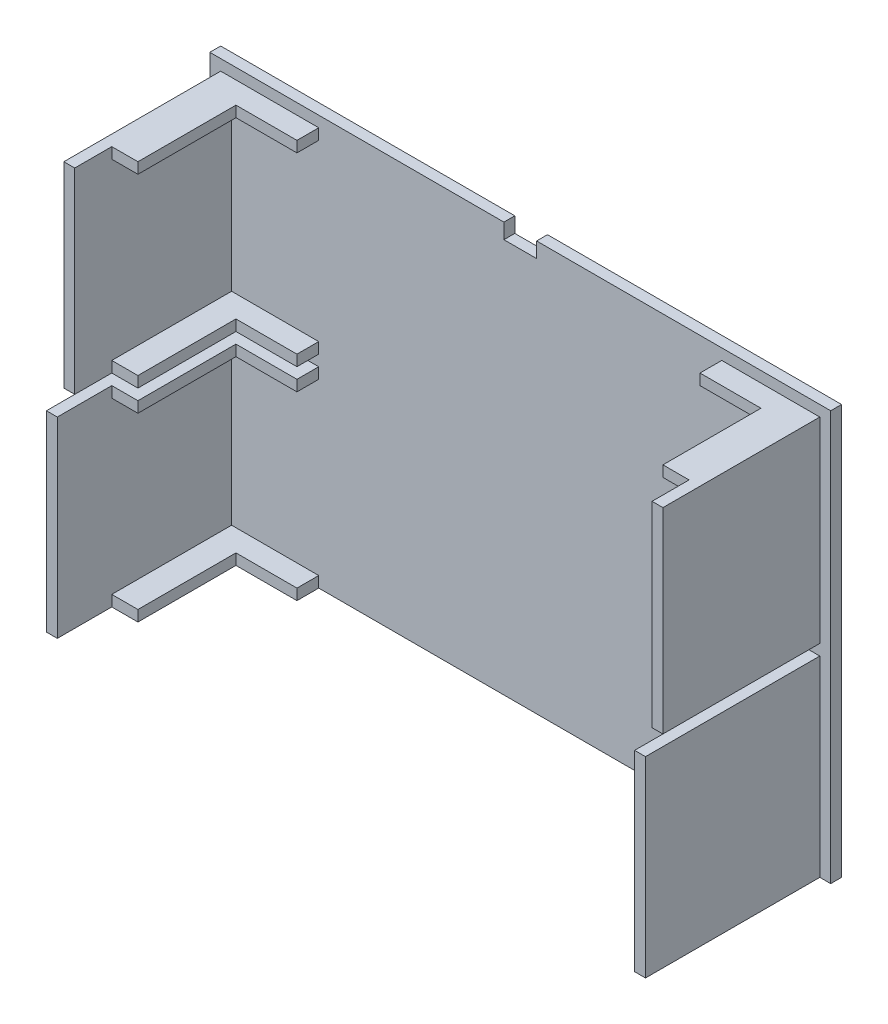
from build123d import *

# Parameters (mm, degrees)
SKETCH1_W                = 285
SKETCH1_H                = 188
BOSS_EXTRUDE1_DEPTH      = 5
SKETCH3_W                = 5
SKETCH3_H                = 90
BOSS_EXTRUDE2_DEPTH      = 72
SKETCH6_W                = 40
SKETCH6_H                = 5
BOSS_EXTRUDE3_DEPTH      = 10
SKETCH7_W                = 12
SKETCH7_H                = 5
BOSS_EXTRUDE4_DEPTH      = 45
SKETCH8_W                = 40
SKETCH8_H                = 5
BOSS_EXTRUDE5_DEPTH      = 72
CUT_EXTRUDE4_DEPTH       = 94
CUT_EXTRUDE4_DEPTH_BACK  = 96
SKETCH13_W               = 5
SKETCH13_H               = 90
BOSS_EXTRUDE6_DEPTH      = 72
SKETCH14_W               = 40
SKETCH14_H               = 5
BOSS_EXTRUDE7_DEPTH      = 55
SKETCH16_W               = 28
SKETCH16_H               = 45
CUT_EXTRUDE5_DEPTH       = 179
CUT_EXTRUDE5_DEPTH_BACK  = 11
SKETCH17_W               = 40
SKETCH17_H               = 5
BOSS_EXTRUDE9_DEPTH      = 55
SKETCH21_W               = 27.761976985
SKETCH21_H               = 40
CUT_EXTRUDE6_DEPTH       = 91
CUT_EXTRUDE6_DEPTH_BACK  = 99
SKETCH22_W               = 5
SKETCH22_H               = 88
BOSS_EXTRUDE10_DEPTH     = 80
SKETCH23_W               = 40
SKETCH23_H               = 5
BOSS_EXTRUDE11_DEPTH     = 55
SKETCH25_W               = 27.891782469
SKETCH25_H               = 44.37316573
CUT_EXTRUDE7_DEPTH       = 184
CUT_EXTRUDE7_DEPTH_BACK  = 6
SKETCH26_W               = 40
SKETCH26_H               = 5
BOSS_EXTRUDE12_DEPTH     = 55
SKETCH27_W               = 28
SKETCH27_H               = 45
CUT_EXTRUDE9_DEPTH       = 101
CUT_EXTRUDE9_DEPTH_BACK  = 89
SKETCH29_W               = 5
SKETCH29_H               = 88
BOSS_EXTRUDE14_DEPTH     = 80
SKETCH30_W               = 40
SKETCH30_H               = 5
BOSS_EXTRUDE15_DEPTH     = 55
SKETCH31_W               = 27.846515173
SKETCH31_H               = 45
CUT_EXTRUDE10_DEPTH      = 184
CUT_EXTRUDE10_DEPTH_BACK = 6
SKETCH32_W               = 40
SKETCH32_H               = 5
BOSS_EXTRUDE16_DEPTH     = 55
SKETCH33_W               = 27.846515173
SKETCH33_H               = 45
CUT_EXTRUDE11_DEPTH      = 84
CUT_EXTRUDE11_DEPTH_BACK = 106
SKETCH36_W               = 15
SKETCH36_H               = 5
CUT_EXTRUDE12_DEPTH      = 1
CUT_EXTRUDE12_DEPTH_BACK = 7


with BuildPart() as part:
    # Sketch1 → Boss-Extrude1 (new body)
    with BuildSketch(Plane.XY):
        with Locations((3.734064661, -18.883040936)):
            Rectangle(SKETCH1_W, SKETCH1_H)
    extrude(amount=BOSS_EXTRUDE1_DEPTH)

    # Sketch3 → Boss-Extrude2 (add)
    with BuildSketch(Plane.XY.offset(5)):
        with Locations((-131.265935339, 25.116959064)):
            Rectangle(SKETCH3_W, SKETCH3_H)
    extrude(amount=BOSS_EXTRUDE2_DEPTH)

    # Sketch6 → Boss-Extrude3 (add)
    with BuildSketch(Plane.XY.offset(5)):
        with Locations((-108.765935339, 67.616959064)):
            Rectangle(SKETCH6_W, SKETCH6_H)
    extrude(amount=BOSS_EXTRUDE3_DEPTH)

    # Sketch7 → Boss-Extrude4 (add)
    with BuildSketch(Plane.XY.offset(15)):
        with Locations((-122.765935339, 67.616959064)):
            Rectangle(SKETCH7_W, SKETCH7_H)
    extrude(amount=BOSS_EXTRUDE4_DEPTH)

    # Sketch8 → Boss-Extrude5 (add)
    with BuildSketch(Plane.XY.offset(77)):
        with Locations((-108.765935339, -17.383040936)):
            Rectangle(SKETCH8_W, SKETCH8_H)
    extrude(amount=-BOSS_EXTRUDE5_DEPTH)

    # Sketch9 → Cut-Extrude4 (cut, two sides)
    with BuildSketch(Plane.XZ.offset(19.883040936)) as cut_extrude4_sk:
        Polygon((-116.765935339, 15), (-88.765935339, 15), (-88.765935339, 77), (-128.765935339, 77), (-128.765935339, 60), (-116.765935339, 60), align=None)
    extrude(amount=CUT_EXTRUDE4_DEPTH, mode=Mode.SUBTRACT)
    extrude(cut_extrude4_sk.sketch, amount=-CUT_EXTRUDE4_DEPTH_BACK, mode=Mode.SUBTRACT)

    # Sketch13 → Boss-Extrude6 (add)
    with BuildSketch(Plane.XY.offset(5)):
        with Locations((138.734064661, 25.116959064)):
            Rectangle(SKETCH13_W, SKETCH13_H)
    extrude(amount=BOSS_EXTRUDE6_DEPTH)

    # Sketch14 → Boss-Extrude7 (add)
    with BuildSketch(Plane.XY.offset(5)):
        with Locations((116.234064661, 67.616959064)):
            Rectangle(SKETCH14_W, SKETCH14_H)
    extrude(amount=BOSS_EXTRUDE7_DEPTH)

    # Sketch16 → Cut-Extrude5 (cut, two sides)
    with BuildSketch(Plane.XZ.offset(-65.116959064)) as cut_extrude5_sk:
        with Locations((110.234064661, 37.5)):
            Rectangle(SKETCH16_W, SKETCH16_H)
    extrude(amount=CUT_EXTRUDE5_DEPTH, mode=Mode.SUBTRACT)
    extrude(cut_extrude5_sk.sketch, amount=-CUT_EXTRUDE5_DEPTH_BACK, mode=Mode.SUBTRACT)

    # Sketch17 → Boss-Extrude9 (add)
    with BuildSketch(Plane.XY):
        with Locations((116.234064661, -17.383040936)):
            Rectangle(SKETCH17_W, SKETCH17_H)
    extrude(amount=BOSS_EXTRUDE9_DEPTH)

    # Sketch21 → Cut-Extrude6 (cut, two sides)
    with BuildSketch(Plane(origin=(0, -14.883040936, 0), x_dir=(1, 0, 0), z_dir=(0, 1, 0))) as cut_extrude6_sk:
        with Locations((110.115053154, -35)):
            Rectangle(SKETCH21_W, SKETCH21_H)
    extrude(amount=CUT_EXTRUDE6_DEPTH, mode=Mode.SUBTRACT)
    extrude(cut_extrude6_sk.sketch, amount=-CUT_EXTRUDE6_DEPTH_BACK, mode=Mode.SUBTRACT)

    # Sketch22 → Boss-Extrude10 (add)
    with BuildSketch(Plane.XY.offset(5)):
        with Locations((-131.265935339, -68.883040936)):
            Rectangle(SKETCH22_W, SKETCH22_H)
    extrude(amount=BOSS_EXTRUDE10_DEPTH)

    # Sketch23 → Boss-Extrude11 (add)
    with BuildSketch(Plane.XY.offset(5)):
        with Locations((-108.765935339, -110.383040936)):
            Rectangle(SKETCH23_W, SKETCH23_H)
    extrude(amount=BOSS_EXTRUDE11_DEPTH)

    # Sketch25 → Cut-Extrude7 (cut, two sides)
    with BuildSketch(Plane(origin=(0, -107.883040936, 0), x_dir=(1, 0, 0), z_dir=(0, 1, 0))) as cut_extrude7_sk:
        with Locations((-102.711826574, -37.813417135)):
            Rectangle(SKETCH25_W, SKETCH25_H)
    extrude(amount=CUT_EXTRUDE7_DEPTH, mode=Mode.SUBTRACT)
    extrude(cut_extrude7_sk.sketch, amount=-CUT_EXTRUDE7_DEPTH_BACK, mode=Mode.SUBTRACT)

    # Sketch26 → Boss-Extrude12 (add)
    with BuildSketch(Plane.XY.offset(5)):
        with Locations((-108.765935339, -27.383040936)):
            Rectangle(SKETCH26_W, SKETCH26_H)
    extrude(amount=BOSS_EXTRUDE12_DEPTH)

    # Sketch27 → Cut-Extrude9 (cut, two sides)
    with BuildSketch(Plane(origin=(0, -24.883040936, 0), x_dir=(1, 0, 0), z_dir=(0, 1, 0))) as cut_extrude9_sk:
        with Locations((-102.765935339, -37.5)):
            Rectangle(SKETCH27_W, SKETCH27_H)
    extrude(amount=CUT_EXTRUDE9_DEPTH, mode=Mode.SUBTRACT)
    extrude(cut_extrude9_sk.sketch, amount=-CUT_EXTRUDE9_DEPTH_BACK, mode=Mode.SUBTRACT)

    # Sketch29 → Boss-Extrude14 (add)
    with BuildSketch(Plane.XY.offset(5)):
        with Locations((138.734064661, -68.883040936)):
            Rectangle(SKETCH29_W, SKETCH29_H)
    extrude(amount=BOSS_EXTRUDE14_DEPTH)

    # Sketch30 → Boss-Extrude15 (add)
    with BuildSketch(Plane.XY.offset(5)):
        with Locations((116.234064661, -110.383040936)):
            Rectangle(SKETCH30_W, SKETCH30_H)
    extrude(amount=BOSS_EXTRUDE15_DEPTH)

    # Sketch31 → Cut-Extrude10 (cut, two sides)
    with BuildSketch(Plane(origin=(0, -107.883040936, 0), x_dir=(1, 0, 0), z_dir=(0, 1, 0))) as cut_extrude10_sk:
        with Locations((110.157322248, -37.5)):
            Rectangle(SKETCH31_W, SKETCH31_H)
    extrude(amount=CUT_EXTRUDE10_DEPTH, mode=Mode.SUBTRACT)
    extrude(cut_extrude10_sk.sketch, amount=-CUT_EXTRUDE10_DEPTH_BACK, mode=Mode.SUBTRACT)

    # Sketch32 → Boss-Extrude16 (add)
    with BuildSketch(Plane.XY.offset(5)):
        with Locations((116.234064661, -27.383040936)):
            Rectangle(SKETCH32_W, SKETCH32_H)
    extrude(amount=BOSS_EXTRUDE16_DEPTH)

    # Sketch33 → Cut-Extrude11 (cut, two sides)
    with BuildSketch(Plane.XZ.offset(29.883040936)) as cut_extrude11_sk:
        with Locations((110.157322248, 37.5)):
            Rectangle(SKETCH33_W, SKETCH33_H)
    extrude(amount=CUT_EXTRUDE11_DEPTH, mode=Mode.SUBTRACT)
    extrude(cut_extrude11_sk.sketch, amount=-CUT_EXTRUDE11_DEPTH_BACK, mode=Mode.SUBTRACT)

    # Sketch36 → Cut-Extrude12 (cut, two sides)
    with BuildSketch(Plane(origin=(0, 75.116959064, 0), x_dir=(1, 0, 0), z_dir=(0, 1, 0))) as cut_extrude12_sk:
        with Locations((3.734064661, -2.5)):
            Rectangle(SKETCH36_W, SKETCH36_H)
    extrude(amount=CUT_EXTRUDE12_DEPTH, mode=Mode.SUBTRACT)
    extrude(cut_extrude12_sk.sketch, amount=-CUT_EXTRUDE12_DEPTH_BACK, mode=Mode.SUBTRACT)


solid = part.part
